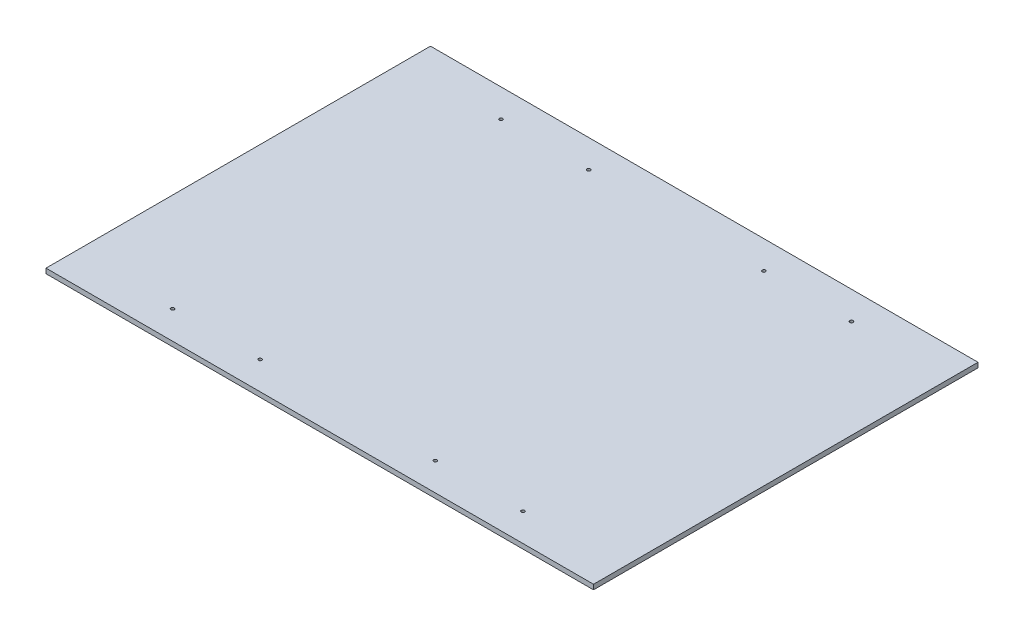
from build123d import *

# Parameters (mm, degrees)
SKETCH1_W           = 714.375
SKETCH1_H           = 501.65
BOSS_EXTRUDE1_DEPTH = 6.35
SKETCH2_R           = 2.15265
CUT_EXTRUDE1_DEPTH  = 7.35


with BuildPart() as part:
    # Sketch1 → Boss-Extrude1 (new body)
    with BuildSketch(Plane(origin=(0, 0, 0), x_dir=(1, 0, 0), z_dir=(0, 1, 0))):
        Rectangle(SKETCH1_W, SKETCH1_H)
    extrude(amount=BOSS_EXTRUDE1_DEPTH)

    # Sketch2 → Cut-Extrude1 (cut, through all)
    with BuildSketch(Plane(origin=(0, 6.35, 0), x_dir=(1, 0, 0), z_dir=(0, 1, 0))):
        with Locations((-114.3, -214.3125)):
            Circle(SKETCH2_R)
        with Locations((-228.6, -214.3125)):
            Circle(SKETCH2_R)
        with Locations((228.6, -214.3125)):
            Circle(SKETCH2_R)
        with Locations((114.3, -214.3125)):
            Circle(SKETCH2_R)
        with Locations((114.3, 214.3125)):
            Circle(SKETCH2_R)
        with Locations((228.6, 214.3125)):
            Circle(SKETCH2_R)
        with Locations((-228.6, 214.3125)):
            Circle(SKETCH2_R)
        with Locations((-114.3, 214.3125)):
            Circle(SKETCH2_R)
    extrude(amount=-CUT_EXTRUDE1_DEPTH, mode=Mode.SUBTRACT)


solid = part.part
